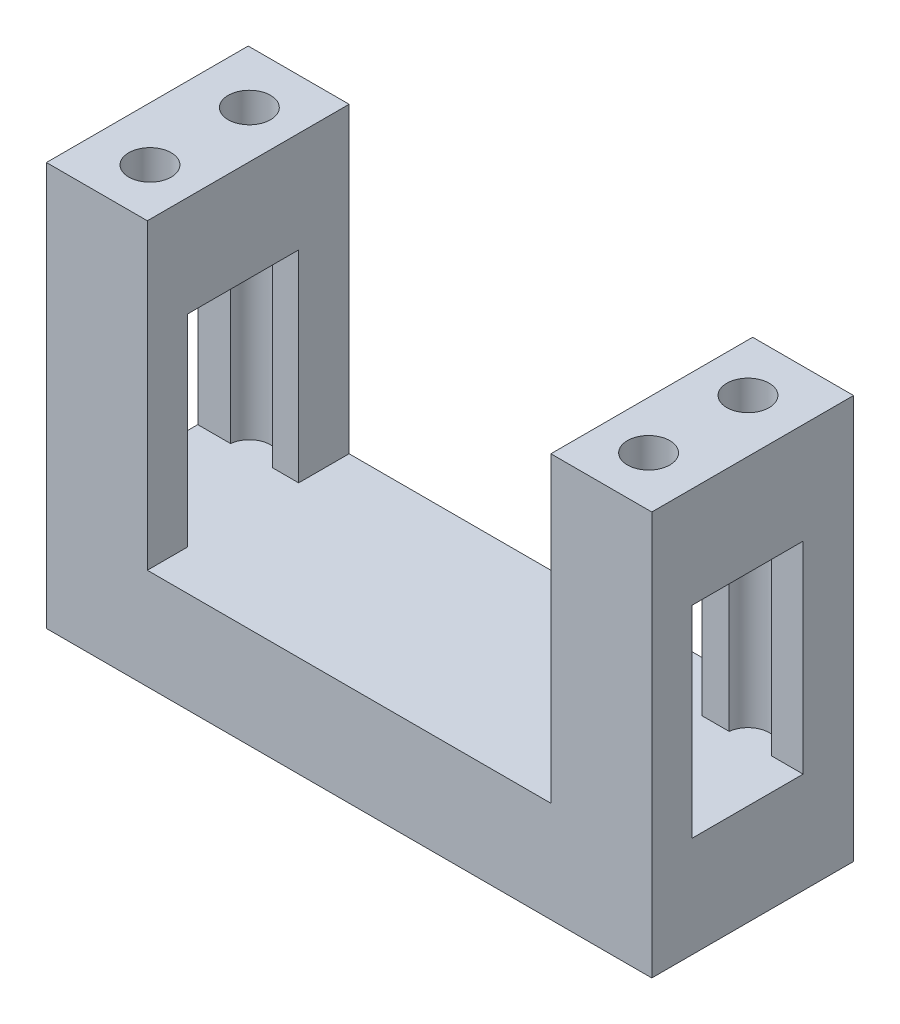
from build123d import *

# Parameters (mm, degrees)
SKIZZE1_W                       = 60
SKIZZE1_H                       = 40
AUFSATZ_LINEAR_AUSTRAGEN1_DEPTH = 20
SKIZZE2_W                       = 40
SKIZZE2_H                       = 20
SCHNITT_LINEAR_AUSTRAGEN1_DEPTH = 30
SKIZZE3_W                       = 11
SKIZZE3_H                       = 20
SCHNITT_LINEAR_AUSTRAGEN2_DEPTH = 61
SKIZZE4_R                       = 2.1
SCHNITT_LINEAR_AUSTRAGEN3_DEPTH = 30


with BuildPart() as part:
    # Skizze1 → Aufsatz-Linear austragen1 (new body)
    with BuildSketch(Plane.XY):
        with Locations((30, 20)):
            Rectangle(SKIZZE1_W, SKIZZE1_H)
    extrude(amount=AUFSATZ_LINEAR_AUSTRAGEN1_DEPTH)

    # Skizze2 → Schnitt-Linear austragen1 (cut)
    with BuildSketch(Plane(origin=(0, 40, 0), x_dir=(1, 0, 0), z_dir=(0, 1, 0))):
        with Locations((30, -10)):
            Rectangle(SKIZZE2_W, SKIZZE2_H)
    extrude(amount=-SCHNITT_LINEAR_AUSTRAGEN1_DEPTH, mode=Mode.SUBTRACT)

    # Skizze3 → Schnitt-Linear austragen2 (cut, through all)
    with BuildSketch(Plane(origin=(60, 0, 0), x_dir=(0, 0, -1), z_dir=(1, 0, 0))):
        with Locations((-10.5, 20)):
            Rectangle(SKIZZE3_W, SKIZZE3_H)
    extrude(amount=-SCHNITT_LINEAR_AUSTRAGEN2_DEPTH, mode=Mode.SUBTRACT)

    # Skizze4 → Schnitt-Linear austragen3 (cut)
    with BuildSketch(Plane(origin=(0, 40, 0), x_dir=(1, 0, 0), z_dir=(0, 1, 0))):
        with Locations((5.338854382, -5.225)):
            Circle(SKIZZE4_R)
        with Locations((5.338854382, -15.075)):
            Circle(SKIZZE4_R)
        with Locations((54.761145618, -15.075)):
            Circle(SKIZZE4_R)
        with Locations((54.761145618, -5.225)):
            Circle(SKIZZE4_R)
    extrude(amount=-SCHNITT_LINEAR_AUSTRAGEN3_DEPTH, mode=Mode.SUBTRACT)


solid = part.part
